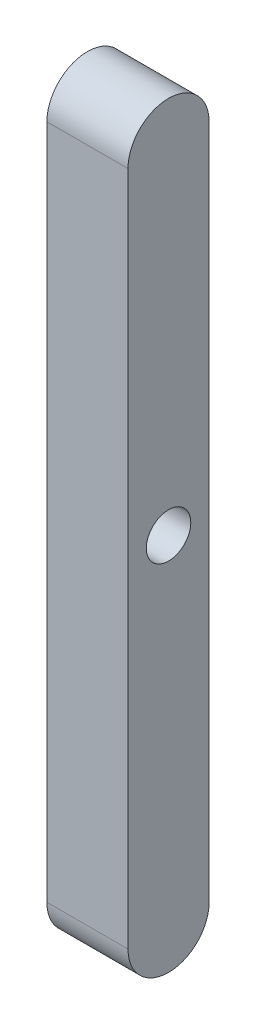
from build123d import *

# Parameters (mm, degrees)
SKETCH_1_R      = 1.644704327
EXTRUDE_1_DEPTH = 6


with BuildPart() as part:
    # 草图1 → 凸台-拉伸1 (new body)
    with BuildSketch(Plane(origin=(0, 0, 0), x_dir=(0, 0, -1), z_dir=(1, 0, 0))):
        with BuildLine():
            Line((-3, -25), (-3, 25))
            ThreePointArc((-3, 25), (0, 28), (3, 25))
            Line((3, 25), (3, -25))
            ThreePointArc((3, -25), (0, -28), (-3, -25))
        make_face()
        Circle(SKETCH_1_R, mode=Mode.SUBTRACT)
    extrude(amount=EXTRUDE_1_DEPTH)


solid = part.part
